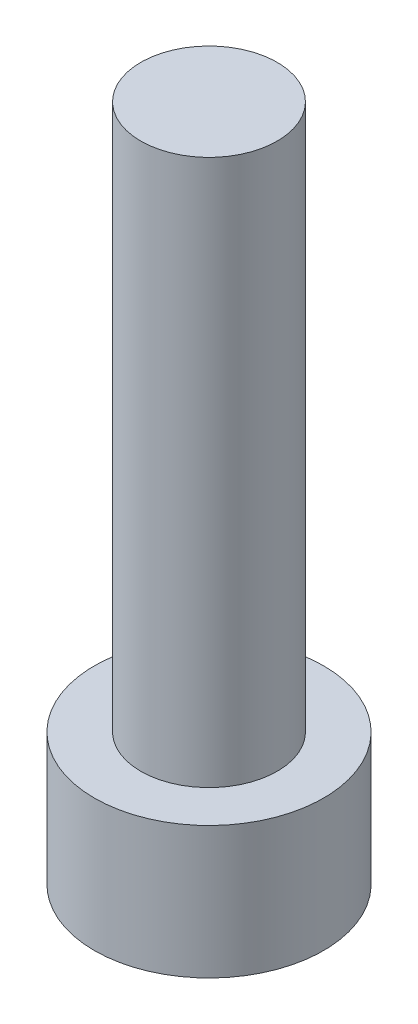
from build123d import *

# Parameters (mm, degrees)
SKETCH_1_R          = 4.2
EXTRUDE_1_DEPTH     = 4.84
SKETCH_2_R          = 2.5
EXTRUDE_2_DEPTH     = 20
CUT_EXTRUDE_1_DEPTH = 3.4


with BuildPart() as part:
    # 草图1 → 凸台-拉伸1 (new body)
    with BuildSketch(Plane(origin=(0, 0, 0), x_dir=(1, 0, 0), z_dir=(0, 1, 0))):
        Circle(SKETCH_1_R)
    extrude(amount=EXTRUDE_1_DEPTH)

    # 草图2 → 凸台-拉伸2 (add)
    with BuildSketch(Plane(origin=(0, 4.84, 0), x_dir=(1, 0, 0), z_dir=(0, 1, 0))):
        Circle(SKETCH_2_R)
    extrude(amount=EXTRUDE_2_DEPTH)

    # 草图3 → 切除-拉伸1 (cut)
    with BuildSketch(Plane.XZ):
        Polygon((2.3, 0), (1.15, 1.991858429), (-1.15, 1.991858429), (-2.3, 0), (-1.15, -1.991858429), (1.15, -1.991858429), align=None)
    extrude(amount=-CUT_EXTRUDE_1_DEPTH, mode=Mode.SUBTRACT)


solid = part.part
